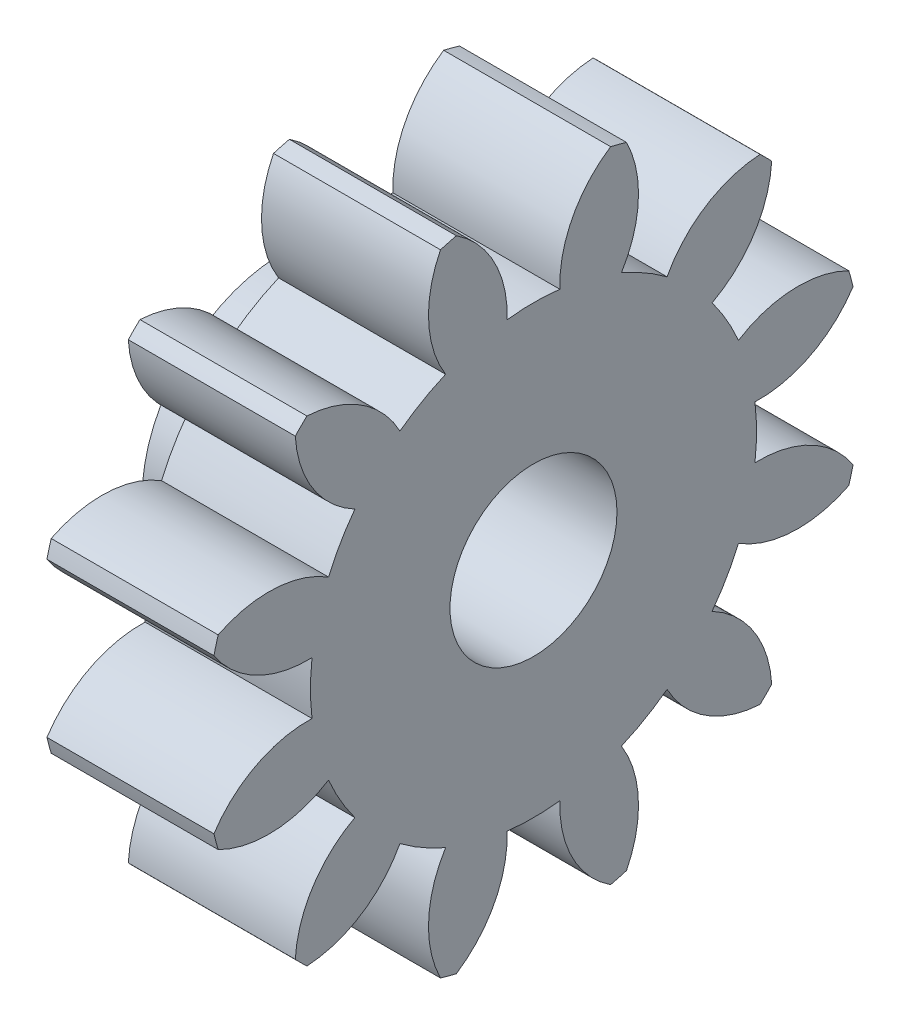
from build123d import *

# Parameters (mm, degrees)
BASPROSKE_W         = 4
BASPROSKE_H         = 7.875
TOOTHCUT_DEPTH      = 12.833480046
TEETHCUTS_COUNT     = 12
TEETHCUTS_ANGLE     = 330
BORSKE_R            = 1
BORE_DEPTH          = 50.0000508
SKETCH1_R           = 3.375
SKETCH1_R_2         = 2.375
BOSS_EXTRUDE1_DEPTH = 2
SKETCH2_R           = 2
CUT_EXTRUDE1_DEPTH  = 3


with BuildPart() as part:
    # BasProSke → Base-Revolve (revolve)
    with BuildSketch(Plane(origin=(0, 0, 0), x_dir=(1, 0, 0), z_dir=(0, 1, 0)), mode=Mode.PRIVATE) as base_revolve_sk:
        with Locations((2, 3.9375)):
            Rectangle(BASPROSKE_W, BASPROSKE_H)
    revolve(base_revolve_sk.sketch.rotate(Axis((-10, 0, 0), (1, 0, 0)), 180), axis=Axis((-10, 0, 0), (1, 0, 0)))

    # TooCutSke → ToothCut (cut, through all)
    with BuildSketch(Plane(origin=(0, 0, 0), x_dir=(0, 0, -1), z_dir=(1, 0, 0))):
        with BuildLine():
            ThreePointArc((0.631439839, 5.305305014), (0, 5.34275), (-0.631439839, 5.305305014))
            ThreePointArc((-0.631439839, 5.305305014), (-0.93992237, 6.654932089), (-1.876748184, 7.674251521))
            ThreePointArc((-1.876748184, 7.674251521), (0, 7.9004), (1.876748184, 7.674251521))
            ThreePointArc((1.876748184, 7.674251521), (0.93992237, 6.654932089), (0.631439839, 5.305305014))
        make_face()
    toothcut = extrude(amount=TOOTHCUT_DEPTH, mode=Mode.SUBTRACT)

    # TeethCuts: ToothCut ×12 about axis
    teethcuts_axis = Axis((-10, 0, 0), (1, 0, 0))
    for i in range(1, TEETHCUTS_COUNT):
        add(toothcut.rotate(teethcuts_axis, i * TEETHCUTS_ANGLE / (TEETHCUTS_COUNT - 1)), mode=Mode.SUBTRACT)

    # BorSke → Bore (cut, symmetric)
    with BuildSketch(Plane(origin=(0, 0, 0), x_dir=(0, 0, -1), z_dir=(1, 0, 0))):
        with Locations(Location((0, 0, 0), (0, 0, 180))):
            Circle(BORSKE_R)
    extrude(amount=BORE_DEPTH, both=True, mode=Mode.SUBTRACT)

    # Sketch1 → Boss-Extrude1 (add)
    with BuildSketch(Plane.ZY):
        with Locations(Location((0, 0, 0), (0, 0, 180))):
            Circle(SKETCH1_R)
        Circle(SKETCH1_R_2, mode=Mode.SUBTRACT)
    extrude(amount=BOSS_EXTRUDE1_DEPTH)

    # Sketch2 → Cut-Extrude1 (cut)
    with BuildSketch(Plane(origin=(4, 0, 0), x_dir=(0, 0, -1), z_dir=(1, 0, 0))):
        Circle(SKETCH2_R)
    extrude(amount=-CUT_EXTRUDE1_DEPTH, mode=Mode.SUBTRACT)


solid = part.part
